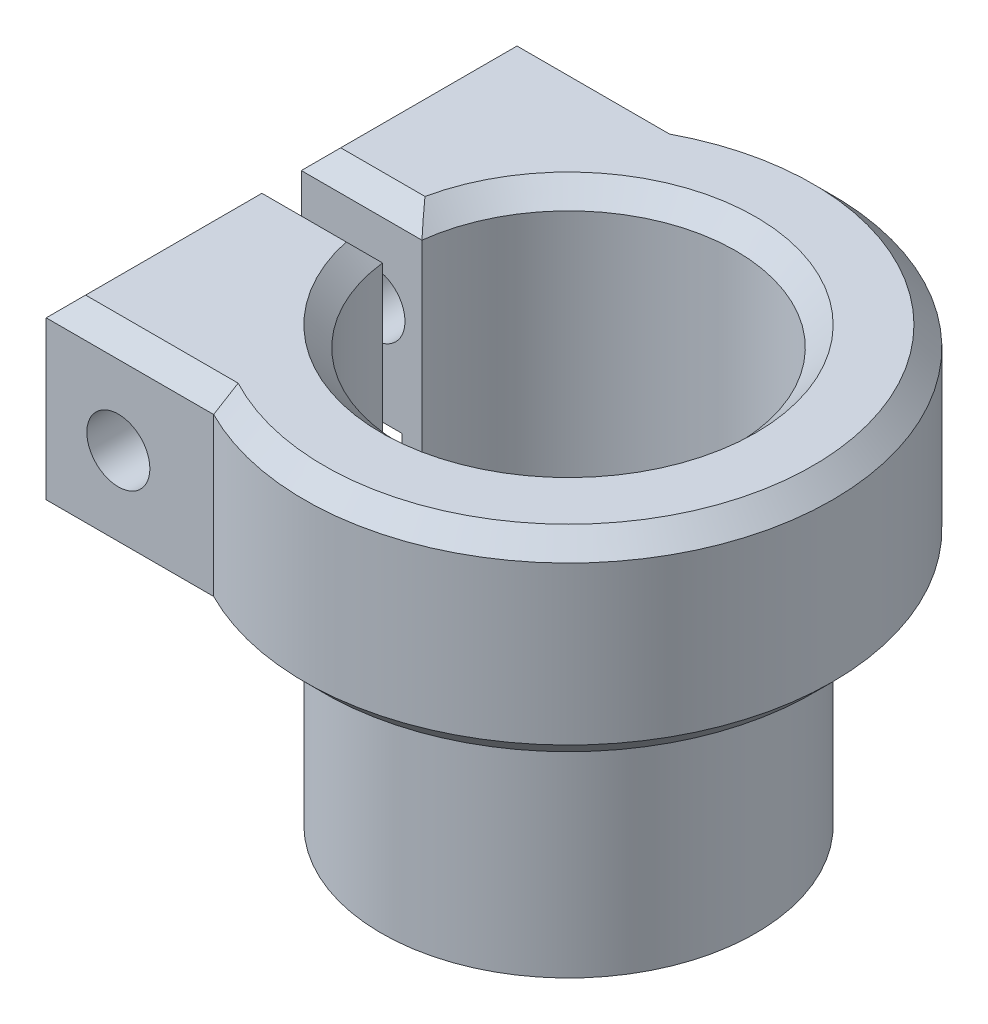
from build123d import *

# Parameters (mm, degrees)
SKETCH1_R               = 9.5
SKETCH1_R_2             = 8.5
BOSS_EXTRUDE1_DEPTH     = 12
SKETCH2_R               = 13.4
SKETCH2_R_2             = 8.5
BOSS_EXTRUDE2_DEPTH     = 10
SKETCH3_W               = 2
SKETCH3_H               = 22
CUT_EXTRUDE1_DEPTH      = 21
BOSS_EXTRUDE3_DEPTH     = 10
SKETCH4_R               = 1.6
CUT_EXTRUDE2_DEPTH      = 21
CUT_EXTRUDE2_DEPTH_BACK = 21
CHAMFER1_SIZE           = 1


with BuildPart() as part:
    # Sketch1 → Boss-Extrude1 (new body)
    with BuildSketch(Plane(origin=(0, 0, 0), x_dir=(1, 0, 0), z_dir=(0, 1, 0))):
        Circle(SKETCH1_R)
        Circle(SKETCH1_R_2, mode=Mode.SUBTRACT)
    extrude(amount=BOSS_EXTRUDE1_DEPTH)

    # Sketch2 → Boss-Extrude2 (add)
    with BuildSketch(Plane(origin=(0, 12, 0), x_dir=(1, 0, 0), z_dir=(0, 1, 0))):
        Circle(SKETCH2_R)
        Circle(SKETCH2_R_2, mode=Mode.SUBTRACT)
    extrude(amount=BOSS_EXTRUDE2_DEPTH)

    # Sketch3 → Cut-Extrude1 (cut)
    with BuildSketch(Plane(origin=(0, 0, 0), x_dir=(0, 0, -1), z_dir=(1, 0, 0))):
        with Locations((0, 11)):
            Rectangle(SKETCH3_W, SKETCH3_H)
    extrude(amount=-CUT_EXTRUDE1_DEPTH, mode=Mode.SUBTRACT)

    # Sketch6 → Boss-Extrude3 (add)
    with BuildSketch(Plane(origin=(0, 22, 0), x_dir=(1, 0, 0), z_dir=(0, 1, 0))):
        Polygon((-9.518301515, -1), (-14.563720806, -1), (-14.563720806, -11.949530953), (-6.063720806, -11.949530953), align=None)
        Polygon((-6.063720806, 11.949530953), (-14.563720806, 11.949530953), (-14.563720806, 1), (-9.518301515, 1), align=None)
    extrude(amount=-BOSS_EXTRUDE3_DEPTH)

    # Sketch4 → Cut-Extrude2 (cut, two sides)
    with BuildSketch(Plane.XY.offset(-1)) as cut_extrude2_sk:
        with Locations((-10.901802989, 17)):
            Circle(SKETCH4_R)
    extrude(amount=CUT_EXTRUDE2_DEPTH, mode=Mode.SUBTRACT)
    extrude(cut_extrude2_sk.sketch, amount=-CUT_EXTRUDE2_DEPTH_BACK, mode=Mode.SUBTRACT)

    # Chamfer1
    chamfer1_edges = [part.edges().sort_by_distance(p)[0] for p in [
        (0.500870333, 22, -8.485230045),
        (-11.502346157, 22, 1),
        (-11.502346157, 22, -1),
        (13.4, 22, 0),
        (13.4, 12, 0),
        (-10.313720806, 22, 11.949530953),
        (-14.563720806, 22, 6.474765476),
        (-10.313720806, 12, 11.949530953),
        (-14.563720806, 12, 6.474765476),
        (-10.313720806, 22, -11.949530953),
        (-14.563720806, 22, -6.474765476),
        (-14.563720806, 12, -6.474765476),
        (-10.313720806, 12, -11.949530953),
    ]]
    chamfer(chamfer1_edges, length=CHAMFER1_SIZE)


solid = part.part
